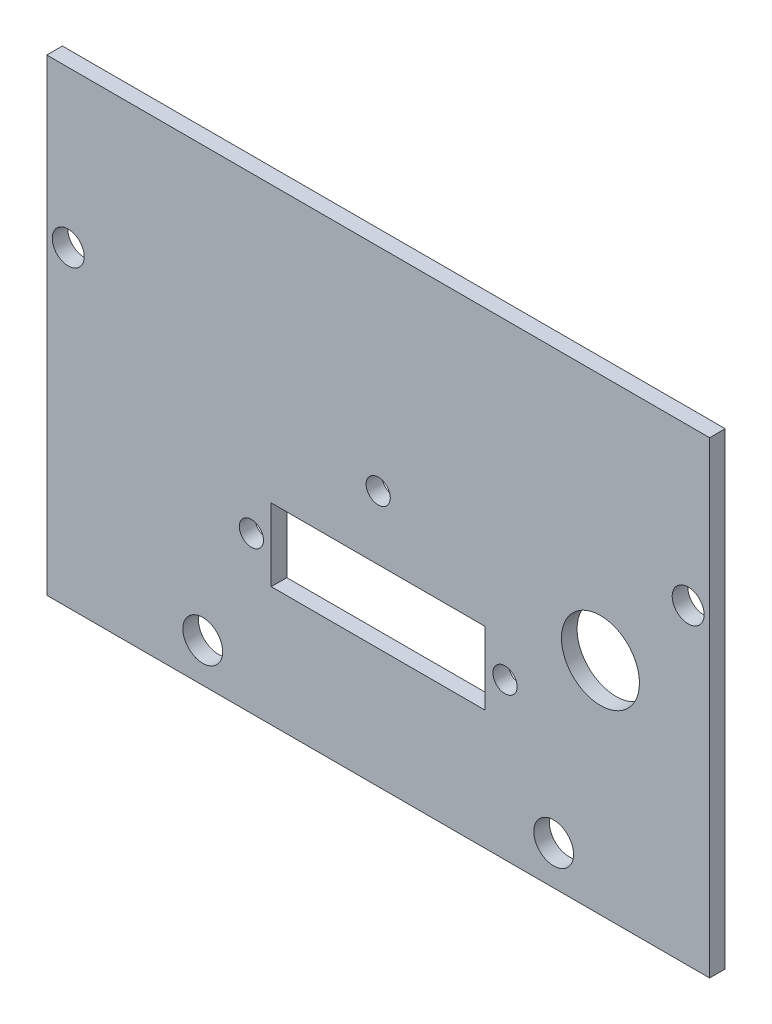
from build123d import *

# Parameters (mm, degrees)
SKETCH1_W           = 85
SKETCH1_H           = 60
BOSS_EXTRUDE1_DEPTH = 2
CUT_EXTRUDE1_REACH  = 4
SKETCH2_R           = 2.55
CUT_EXTRUDE2_REACH  = 4
SKETCH3_R           = 5
SKETCH3_R_2         = 1.55
SKETCH3_W           = 27.44
SKETCH3_H           = 9.3
CUT_EXTRUDE3_REACH  = 4
SKETCH4_R           = 2.05


with BuildPart() as part:
    # Sketch1 → Boss-Extrude1 (new body)
    with BuildSketch(Plane.XY):
        with Locations((-15.192849494, -7.500433728)):
            Rectangle(SKETCH1_W, SKETCH1_H)
    extrude(amount=BOSS_EXTRUDE1_DEPTH)

    # Sketch2 → Cut-Extrude1 (cut, up to next)
    with BuildSketch(Plane(origin=(0, 0, 0), x_dir=(-1, 0, 0), z_dir=(0, 0, -1)), mode=Mode.PRIVATE) as cut_extrude1_sk1:
        with Locations((-7.307150506, -32.500433728)):
            Circle(SKETCH2_R)
    cut_extrude1_tool1 = extrude(cut_extrude1_sk1.sketch, amount=-CUT_EXTRUDE1_REACH, mode=Mode.PRIVATE) & part.part
    add(cut_extrude1_tool1.solids().sort_by_distance((7.307151, -32.500434, 0))[0], mode=Mode.SUBTRACT)
    # Sketch2 → Cut-Extrude1 (cut, up to next)
    with BuildSketch(Plane(origin=(0, 0, 0), x_dir=(-1, 0, 0), z_dir=(0, 0, -1)), mode=Mode.PRIVATE) as cut_extrude1_sk2:
        with Locations((37.692849494, -32.500433728)):
            Circle(SKETCH2_R)
    cut_extrude1_tool2 = extrude(cut_extrude1_sk2.sketch, amount=-CUT_EXTRUDE1_REACH, mode=Mode.PRIVATE) & part.part
    add(cut_extrude1_tool2.solids().sort_by_distance((-37.692849, -32.500434, 0))[0], mode=Mode.SUBTRACT)

    # Sketch3 → Cut-Extrude2 (cut, up to next)
    with BuildSketch(Plane(origin=(0, 0, 0), x_dir=(-1, 0, 0), z_dir=(0, 0, -1)), mode=Mode.PRIVATE) as cut_extrude2_sk1:
        with Locations((-13.307150506, -9.240433728)):
            Circle(SKETCH3_R)
    cut_extrude2_tool1 = extrude(cut_extrude2_sk1.sketch, amount=-CUT_EXTRUDE2_REACH, mode=Mode.PRIVATE) & part.part
    add(cut_extrude2_tool1.solids().sort_by_distance((13.307151, -9.240434, 0))[0], mode=Mode.SUBTRACT)
    # Sketch3 → Cut-Extrude2 (cut, up to next)
    with BuildSketch(Plane(origin=(0, 0, 0), x_dir=(-1, 0, 0), z_dir=(0, 0, -1)), mode=Mode.PRIVATE) as cut_extrude2_sk2:
        with Locations((15.192849494, -4.670433728)):
            Circle(SKETCH3_R_2)
    cut_extrude2_tool2 = extrude(cut_extrude2_sk2.sketch, amount=-CUT_EXTRUDE2_REACH, mode=Mode.PRIVATE) & part.part
    add(cut_extrude2_tool2.solids().sort_by_distance((-15.192849, -4.670434, 0))[0], mode=Mode.SUBTRACT)
    # Sketch3 → Cut-Extrude2 (cut, up to next)
    with BuildSketch(Plane(origin=(0, 0, 0), x_dir=(-1, 0, 0), z_dir=(0, 0, -1)), mode=Mode.PRIVATE) as cut_extrude2_sk3:
        with Locations((-1.067150506, -17.500433728)):
            Circle(SKETCH3_R_2)
    cut_extrude2_tool3 = extrude(cut_extrude2_sk3.sketch, amount=-CUT_EXTRUDE2_REACH, mode=Mode.PRIVATE) & part.part
    add(cut_extrude2_tool3.solids().sort_by_distance((1.067151, -17.500434, 0))[0], mode=Mode.SUBTRACT)
    # Sketch3 → Cut-Extrude2 (cut, up to next)
    with BuildSketch(Plane(origin=(0, 0, 0), x_dir=(-1, 0, 0), z_dir=(0, 0, -1)), mode=Mode.PRIVATE) as cut_extrude2_sk4:
        with Locations((31.452849494, -17.500433728)):
            Circle(SKETCH3_R_2)
    cut_extrude2_tool4 = extrude(cut_extrude2_sk4.sketch, amount=-CUT_EXTRUDE2_REACH, mode=Mode.PRIVATE) & part.part
    add(cut_extrude2_tool4.solids().sort_by_distance((-31.452849, -17.500434, 0))[0], mode=Mode.SUBTRACT)
    # Sketch3 → Cut-Extrude2 (cut, up to next)
    with BuildSketch(Plane(origin=(0, 0, 0), x_dir=(-1, 0, 0), z_dir=(0, 0, -1)), mode=Mode.PRIVATE) as cut_extrude2_sk5:
        with Locations((15.192849494, -17.500433728)):
            Rectangle(SKETCH3_W, SKETCH3_H)
    cut_extrude2_tool5 = extrude(cut_extrude2_sk5.sketch, amount=-CUT_EXTRUDE2_REACH, mode=Mode.PRIVATE) & part.part
    add(cut_extrude2_tool5.solids().sort_by_distance((-15.192849, -17.500434, 0))[0], mode=Mode.SUBTRACT)

    # Sketch4 → Cut-Extrude3 (cut, up to next)
    with BuildSketch(Plane.XY.offset(2), mode=Mode.PRIVATE) as cut_extrude3_sk1:
        with Locations((-54.942849494, 2.499566272)):
            Circle(SKETCH4_R)
    cut_extrude3_tool1 = extrude(cut_extrude3_sk1.sketch, amount=-CUT_EXTRUDE3_REACH, mode=Mode.PRIVATE) & part.part
    add(cut_extrude3_tool1.solids().sort_by_distance((-54.942849, 2.499566, 2))[0], mode=Mode.SUBTRACT)
    # Sketch4 → Cut-Extrude3 (cut, up to next)
    with BuildSketch(Plane.XY.offset(2), mode=Mode.PRIVATE) as cut_extrude3_sk2:
        with Locations((24.557150506, 2.499566272)):
            Circle(SKETCH4_R)
    cut_extrude3_tool2 = extrude(cut_extrude3_sk2.sketch, amount=-CUT_EXTRUDE3_REACH, mode=Mode.PRIVATE) & part.part
    add(cut_extrude3_tool2.solids().sort_by_distance((24.557151, 2.499566, 2))[0], mode=Mode.SUBTRACT)


solid = part.part
